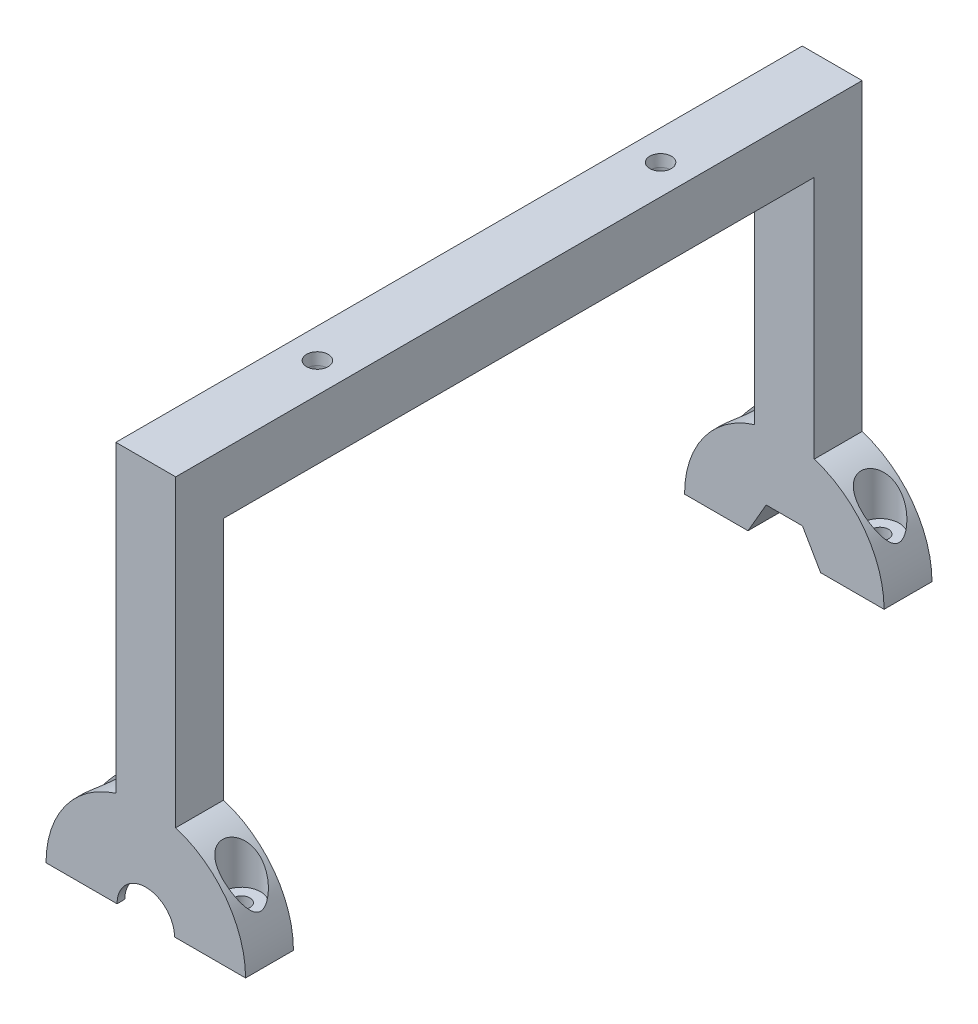
from build123d import *

# Parameters (mm, degrees)
SKETCH2_W                                       = 15
SKETCH2_H                                       = 15
BOSS_EXTRUDE1_DEPTH                             = 86
SKETCH3_W                                       = 15
SKETCH3_H                                       = 12
BOSS_EXTRUDE2_DEPTH                             = 85
BOSS_EXTRUDE3_DEPTH                             = 12
SKETCH6_R                                       = 4.75
SKETCH6_R_2                                     = 2.1
CUT_EXTRUDE1_DEPTH                              = 10
CUT_EXTRUDE1_DIRECTION_2_REACH                  = 82.16
CUT_EXTRUDE2_REACH                              = 21.84
SKETCH6_2_R                                     = 2.1
CSK_FOR_M3_OVAL_HEAD_MACHINE_SCREW1_D           = 5
CSK_FOR_M3_OVAL_HEAD_MACHINE_SCREW1_CSINK_D     = 5.4
CSK_FOR_M3_OVAL_HEAD_MACHINE_SCREW1_CSINK_ANGLE = 8
CUT_EXTRUDE4_REACH                              = 174
SKETCH8_R                                       = 7.2
CUT_EXTRUDE5_START                              = -1.925
SKETCH9_R                                       = 13.1
CUT_EXTRUDE5_DEPTH                              = 8.15
CUT_EXTRUDE6_REACH                              = 174


with BuildPart() as part:
    # Sketch2 → Boss-Extrude1 (new body)
    with BuildSketch(Plane.XY):
        Rectangle(SKETCH2_W, SKETCH2_H)
    extrude(amount=BOSS_EXTRUDE1_DEPTH)

    # Sketch3 → Boss-Extrude2 (add)
    with BuildSketch(Plane.XZ.offset(7.5)):
        with Locations((0, 80)):
            Rectangle(SKETCH3_W, SKETCH3_H)
    extrude(amount=BOSS_EXTRUDE2_DEPTH)

    # Sketch4 → Boss-Extrude3 (add)
    with BuildSketch(Plane.XY.offset(86)):
        with BuildLine():
            Line((-25, -92.5), (25, -92.5))
            ThreePointArc((25, -92.5), (0, -67.5), (-25, -92.5))
        make_face()
    extrude(amount=-BOSS_EXTRUDE3_DEPTH)

    # Sketch6 → Cut-Extrude1 (cut)
    with BuildSketch(Plane(origin=(0, -72.66, 0), x_dir=(-1, 0, 0), z_dir=(0, -1, 0))):
        with Locations((-18, -80)):
            Circle(SKETCH6_R)
        with Locations((-18, -80)):
            Circle(SKETCH6_R_2, mode=Mode.SUBTRACT)
        with Locations((18, -80)):
            Circle(SKETCH6_R)
        with Locations((18, -80)):
            Circle(SKETCH6_R_2, mode=Mode.SUBTRACT)
    extrude(amount=CUT_EXTRUDE1_DEPTH, mode=Mode.SUBTRACT)

    # Sketch6 → Cut-Extrude1 direction 2 (cut, up to next)
    with BuildSketch(Plane(origin=(0, -72.66, 0), x_dir=(-1, 0, 0), z_dir=(0, -1, 0)), mode=Mode.PRIVATE) as cut_extrude1_direction_2_sk1:
        with Locations((-18, -80)):
            Circle(SKETCH6_R)
        with Locations((-18, -80)):
            Circle(SKETCH6_R_2, mode=Mode.SUBTRACT)
    cut_extrude1_direction_2_tool1 = extrude(cut_extrude1_direction_2_sk1.sketch, amount=-CUT_EXTRUDE1_DIRECTION_2_REACH, mode=Mode.PRIVATE) & part.part
    add(cut_extrude1_direction_2_tool1.solids().sort_by_distance((22.61565, -72.66, 80))[0], mode=Mode.SUBTRACT)
    # Sketch6 → Cut-Extrude1 direction 2 (cut, up to next)
    with BuildSketch(Plane(origin=(0, -72.66, 0), x_dir=(-1, 0, 0), z_dir=(0, -1, 0)), mode=Mode.PRIVATE) as cut_extrude1_direction_2_sk2:
        with Locations((18, -80)):
            Circle(SKETCH6_R)
        with Locations((18, -80)):
            Circle(SKETCH6_R_2, mode=Mode.SUBTRACT)
    cut_extrude1_direction_2_tool2 = extrude(cut_extrude1_direction_2_sk2.sketch, amount=-CUT_EXTRUDE1_DIRECTION_2_REACH, mode=Mode.PRIVATE) & part.part
    add(cut_extrude1_direction_2_tool2.solids().sort_by_distance((-13.38435, -72.66, 80))[0], mode=Mode.SUBTRACT)

    # Sketch6_2 → Cut-Extrude2 (cut, up to next)
    with BuildSketch(Plane(origin=(0, -72.66, 0), x_dir=(-1, 0, 0), z_dir=(0, -1, 0)), mode=Mode.PRIVATE) as cut_extrude2_sk1:
        with Locations((-18, -80)):
            Circle(SKETCH6_2_R)
    cut_extrude2_tool1 = extrude(cut_extrude2_sk1.sketch, amount=CUT_EXTRUDE2_REACH, mode=Mode.PRIVATE) & part.part
    add(cut_extrude2_tool1.solids().sort_by_distance((18, -72.66, 80))[0], mode=Mode.SUBTRACT)
    # Sketch6_2 → Cut-Extrude2 (cut, up to next)
    with BuildSketch(Plane(origin=(0, -72.66, 0), x_dir=(-1, 0, 0), z_dir=(0, -1, 0)), mode=Mode.PRIVATE) as cut_extrude2_sk2:
        with Locations((18, -80)):
            Circle(SKETCH6_2_R)
    cut_extrude2_tool2 = extrude(cut_extrude2_sk2.sketch, amount=CUT_EXTRUDE2_REACH, mode=Mode.PRIVATE) & part.part
    add(cut_extrude2_tool2.solids().sort_by_distance((-18, -72.66, 80))[0], mode=Mode.SUBTRACT)

    # CSK for M3 Oval Head Machine Screw1 (through all)
    with Locations(Plane(origin=(0, 7.5, 0), x_dir=(1, 0, 0), z_dir=(0, 1, 0))):
        with Locations((0, -43)):
            CounterSinkHole(CSK_FOR_M3_OVAL_HEAD_MACHINE_SCREW1_D / 2, CSK_FOR_M3_OVAL_HEAD_MACHINE_SCREW1_CSINK_D / 2, counter_sink_angle=CSK_FOR_M3_OVAL_HEAD_MACHINE_SCREW1_CSINK_ANGLE)

    # Mirror1: part across plane


with BuildPart() as part_1:
    add(part.part)
    add(part.part.mirror(Plane.XY))

    # Sketch8 → Cut-Extrude4 (cut, up to next)
    with BuildSketch(Plane.XY.offset(86), mode=Mode.PRIVATE) as cut_extrude4_sk1:
        with Locations((0, -92.5)):
            Circle(SKETCH8_R)
    cut_extrude4_tool1 = extrude(cut_extrude4_sk1.sketch, amount=-CUT_EXTRUDE4_REACH, mode=Mode.PRIVATE) & part_1.part
    add(cut_extrude4_tool1.solids().sort_by_distance((0, -92.5, 86))[0], mode=Mode.SUBTRACT)

    # Sketch9 → Cut-Extrude5 (cut)
    with BuildSketch(Plane.XY.offset(86).offset(CUT_EXTRUDE5_START)):
        with Locations((0, -92.5)):
            Circle(SKETCH9_R)
    extrude(amount=-CUT_EXTRUDE5_DEPTH, mode=Mode.SUBTRACT)

    # Sketch10 → Cut-Extrude6 (cut, up to next)
    with BuildSketch(Plane(origin=(0, 0, -86), x_dir=(-1, 0, 0), z_dir=(0, 0, -1)), mode=Mode.PRIVATE) as cut_extrude6_sk1:
        Polygon((9.1, -92.5), (4.55, -84.619168826), (-4.55, -84.619168826), (-9.1, -92.5), (-4.55, -100.380831174), (4.55, -100.380831174), align=None)
    cut_extrude6_tool1 = extrude(cut_extrude6_sk1.sketch, amount=-CUT_EXTRUDE6_REACH, mode=Mode.PRIVATE) & part_1.part
    add(cut_extrude6_tool1.solids().sort_by_distance((0, -92.5, -86))[0], mode=Mode.SUBTRACT)


solid = part_1.part
